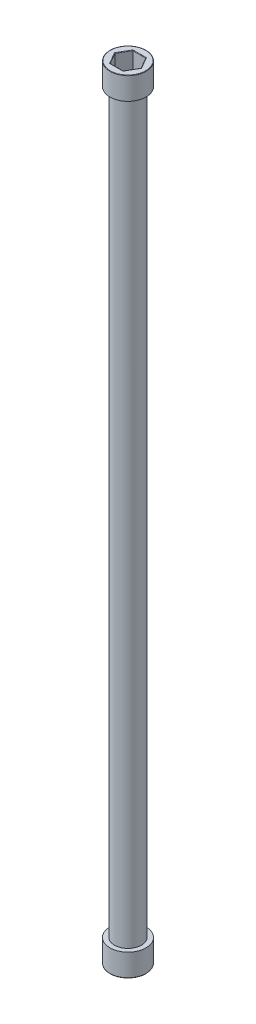
from build123d import *

# Parameters (mm, degrees)
SKETCH2_R            = 3
BOSS_EXTRUDE1_DEPTH  = 81.5
SKETCH4_R            = 4
BOSS_EXTRUDE2_DEPTH  = 5
CUT_EXTRUDE1_DEPTH   = 4
FILLET1_R            = 0.1
FILLET1_OF_MIRROR1_R = 0.1


with BuildPart() as part:
    # Sketch2 → Boss-Extrude1 (new body, symmetric)
    with BuildSketch(Plane(origin=(0, 0, 0), x_dir=(1, 0, 0), z_dir=(0, 1, 0))):
        Circle(SKETCH2_R)
    extrude(amount=BOSS_EXTRUDE1_DEPTH, both=True)

    # Sketch4 → Boss-Extrude2 (add)
    with BuildSketch(Plane(origin=(0, 81.5, 0), x_dir=(1, 0, 0), z_dir=(0, 1, 0))):
        Circle(SKETCH4_R)
    boss_extrude2 = extrude(amount=BOSS_EXTRUDE2_DEPTH)

    # Sketch5 → Cut-Extrude1 (cut)
    with BuildSketch(Plane(origin=(0, 86.5, 0), x_dir=(1, 0, 0), z_dir=(0, 1, 0))):
        Polygon((1.443375673, -2.5), (2.886751346, 0), (1.443375673, 2.5), (-1.443375673, 2.5), (-2.886751346, 0), (-1.443375673, -2.5), align=None)
    cut_extrude1 = extrude(amount=-CUT_EXTRUDE1_DEPTH, mode=Mode.SUBTRACT)

    # Fillet1
    fillet1_edges = [part.edges().sort_by_distance(p)[0] for p in [
        (0, 82.5, 2.5),
        (-2.165063509, 82.5, 1.25),
        (-2.165063509, 82.5, -1.25),
        (0, 82.5, -2.5),
        (2.165063509, 82.5, -1.25),
        (2.165063509, 82.5, 1.25),
        (0, 86.5, 2.5),
        (2.165063509, 86.5, 1.25),
        (2.165063509, 86.5, -1.25),
        (0, 86.5, -2.5),
        (-2.165063509, 86.5, -1.25),
        (-2.165063509, 86.5, 1.25),
        (-4, 86.5, 0),
    ]]
    fillet(fillet1_edges, radius=FILLET1_R)

    # Mirror1: Boss-Extrude2, Cut-Extrude1 across plane
    add(boss_extrude2.mirror(Plane.ZX))
    add(cut_extrude1.mirror(Plane.ZX), mode=Mode.SUBTRACT)

    # Fillet1 of Mirror1
    fillet1_of_mirror1_edges = [part.edges().sort_by_distance(p)[0] for p in [
        (0, -82.5, 2.5),
        (-2.165063509, -82.5, 1.25),
        (-2.165063509, -82.5, -1.25),
        (0, -82.5, -2.5),
        (2.165063509, -82.5, -1.25),
        (2.165063509, -82.5, 1.25),
        (0, -86.5, 2.5),
        (2.165063509, -86.5, 1.25),
        (2.165063509, -86.5, -1.25),
        (0, -86.5, -2.5),
        (-2.165063509, -86.5, -1.25),
        (-2.165063509, -86.5, 1.25),
        (-4, -86.5, 0),
    ]]
    fillet(fillet1_of_mirror1_edges, radius=FILLET1_OF_MIRROR1_R)


solid = part.part
